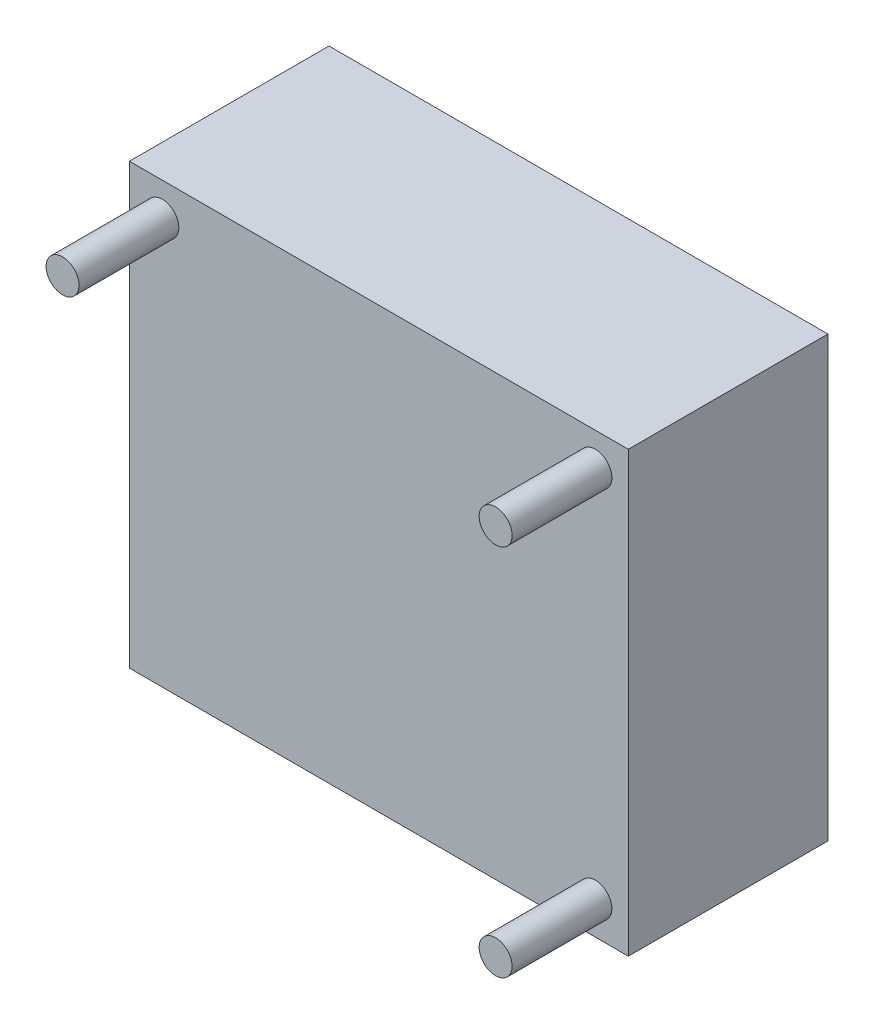
from build123d import *

# Parameters (mm, degrees)
SKETCH1_W             = 50
SKETCH1_H             = 44
SKETCH1_R             = 1.65
BOSS_EXTRUDE1_DEPTH   = 20
SKETCH3_R             = 1.65
BOSS_EXTRUDE2_DEPTH   = 30
BOSS_EXTRUDE2_2_DEPTH = 30
BOSS_EXTRUDE2_3_DEPTH = 30


with BuildPart() as part:
    # Sketch1 → Boss-Extrude1 (new body)
    with BuildSketch(Plane.XY):
        with Locations((25, 22)):
            Rectangle(SKETCH1_W, SKETCH1_H)
        with Locations((46.7, 40.7)):
            Circle(SKETCH1_R, mode=Mode.SUBTRACT)
        with Locations((3.3, 40.7)):
            Circle(SKETCH1_R, mode=Mode.SUBTRACT)
        with Locations((46.7, 3.3)):
            Circle(SKETCH1_R, mode=Mode.SUBTRACT)
    extrude(amount=BOSS_EXTRUDE1_DEPTH)


with BuildPart() as body_2:
    # Sketch3 → Boss-Extrude2 (new body)
    with BuildSketch(Plane(origin=(0, 0, 0), x_dir=(-1, 0, 0), z_dir=(0, 0, -1))):
        with Locations((-46.7, 40.7)):
            Circle(SKETCH3_R)
    extrude(amount=-BOSS_EXTRUDE2_DEPTH)


with BuildPart() as body_3:
    # Sketch3 → Boss-Extrude2 2 (new body)
    with BuildSketch(Plane(origin=(0, 0, 0), x_dir=(-1, 0, 0), z_dir=(0, 0, -1))):
        with Locations((-46.7, 3.3)):
            Circle(SKETCH3_R)
    extrude(amount=-BOSS_EXTRUDE2_2_DEPTH)


with BuildPart() as body_4:
    # Sketch3 → Boss-Extrude2 3 (new body)
    with BuildSketch(Plane(origin=(0, 0, 0), x_dir=(-1, 0, 0), z_dir=(0, 0, -1))):
        with Locations((-3.3, 40.7)):
            Circle(SKETCH3_R)
    extrude(amount=-BOSS_EXTRUDE2_3_DEPTH)


solid = Compound([part.part, body_2.part, body_3.part, body_4.part])
